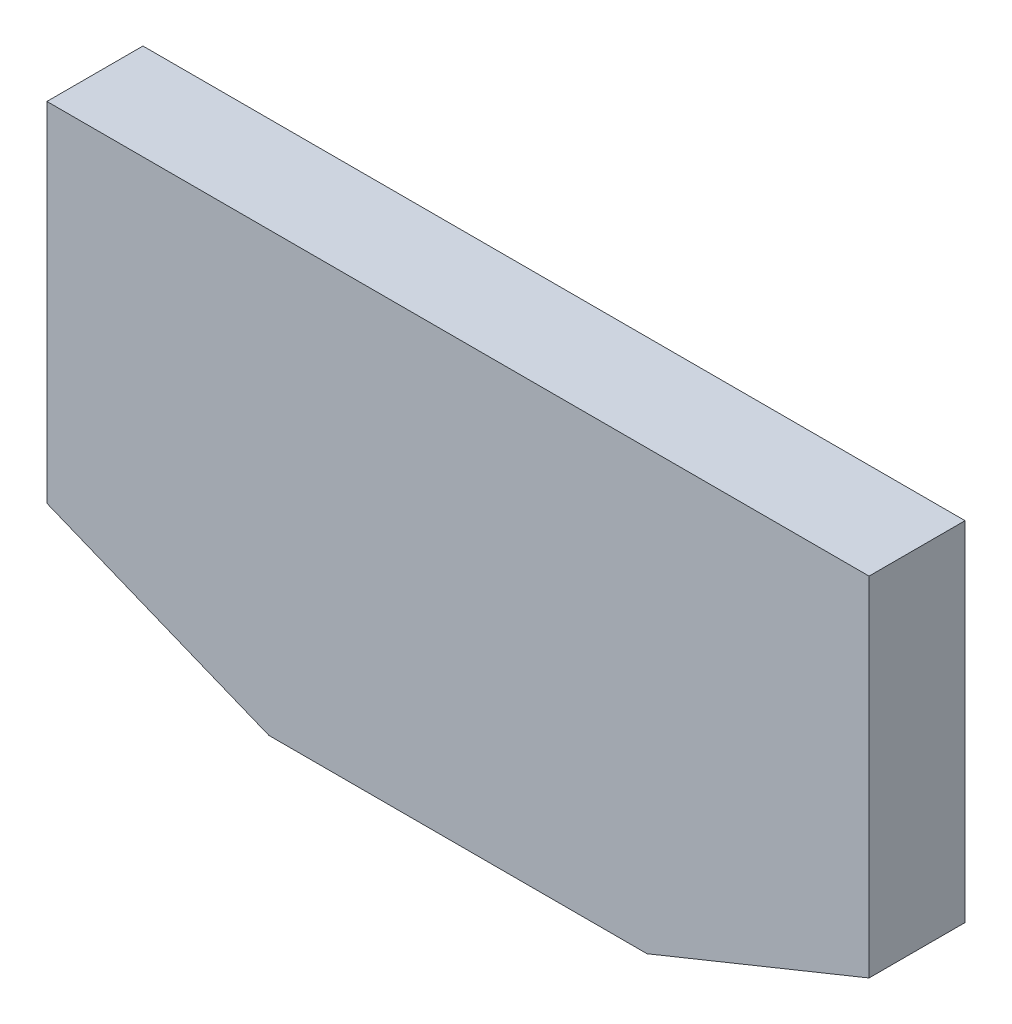
from build123d import *

# Parameters (mm, degrees)
EXTRUDE1_DEPTH = 7
SKETCH2_W      = 685
SKETCH2_H      = 290
EXTRUDE2_DEPTH = 73


with BuildPart() as part:
    # Sketch1 → Extrude1 (new body)
    with BuildSketch(Plane.XY):
        Polygon((0, 75), (185, 0), (500, 0), (685, 75), (685, 365), (0, 365), align=None)
    extrude(amount=EXTRUDE1_DEPTH)

    # Sketch2 → Extrude2 (add)
    with BuildSketch(Plane(origin=(0, 0, 0), x_dir=(-1, 0, 0), z_dir=(0, 0, -1))):
        with Locations((-342.5, 220)):
            Rectangle(SKETCH2_W, SKETCH2_H)
    extrude(amount=EXTRUDE2_DEPTH)


solid = part.part
